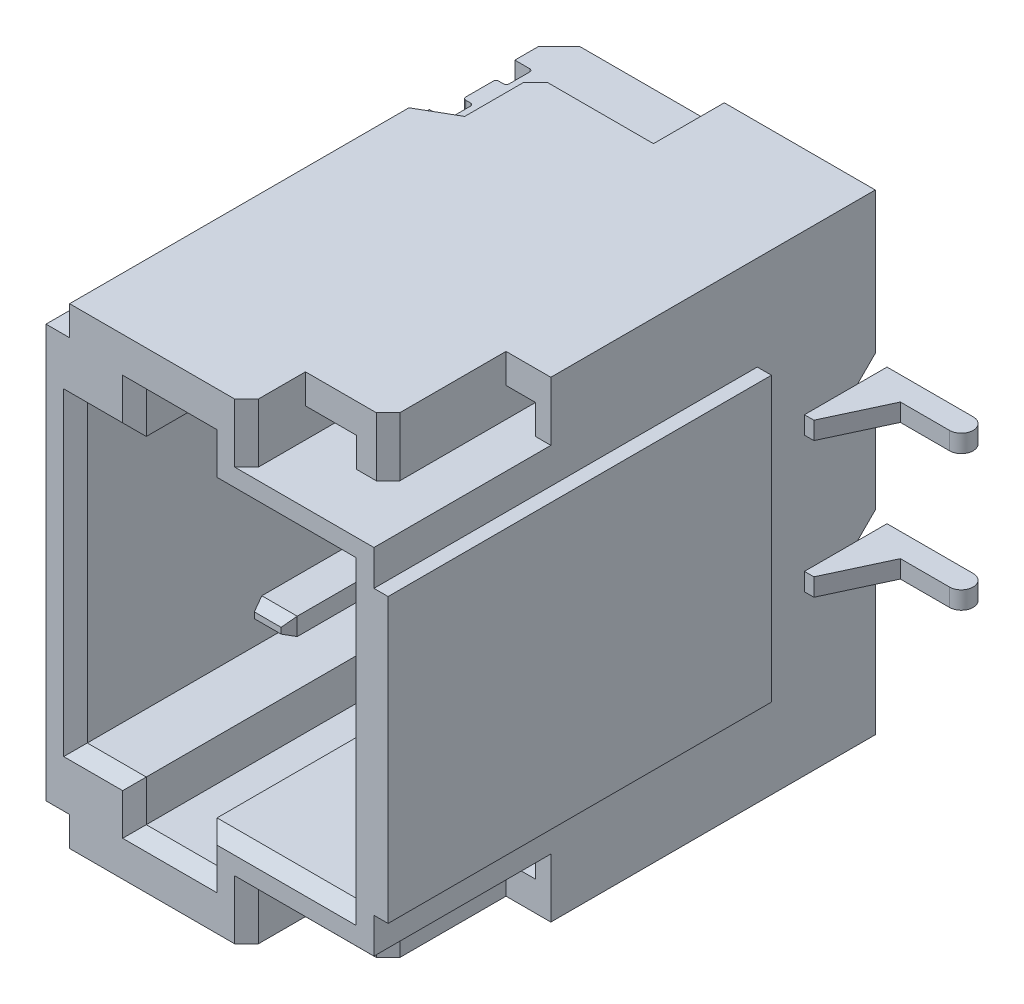
from build123d import *

# Parameters (mm, degrees)
BOSS_EXTRUDE2_START        = -0.815
BOSS_EXTRUDE2_DEPTH        = 0.15
BOSS_EXTRUDE3_START        = 2.26
BOSS_EXTRUDE3_DEPTH        = 0.2
BOSS_EXTRUDE4_START        = 1.76
SKETCH4_W                  = 2.899999619
SKETCH4_H                  = 6
BOSS_EXTRUDE4_DEPTH        = 4.25
SKETCH6_OUTSIDE_W          = 7.998
SKETCH6_OUTSIDE_H          = 9.648
SKETCH6_OUTSIDE_W_2        = 3.400752587
SKETCH6_OUTSIDE_H_2        = 4.399999618
CUT_EXTRUDE3_DEPTH         = 0.12
SKETCH7_W                  = 2.280000687
SKETCH7_H                  = 4.5
CUT_EXTRUDE4_DEPTH         = 3.2
SKETCH8_W                  = 0.600000381
SKETCH8_H                  = 0.349998474
SKETCH8_H_2                = 0.350000382
CUT_EXTRUDE6_DEPTH         = 2.6
CHAMFER1_SIZE              = 0.1
BOSS_EXTRUDE5_START        = -1.82
BOSS_EXTRUDE5_DEPTH        = 0.15
CHAMFER2_SIZE              = 0.1
CHAMFER2_SIZE2             = 0.05
CHAMFER3_SIZE              = 0.05
CHAMFER3_SIZE2             = 0.1
SKETCH10_W                 = 4.538557702
SKETCH10_H                 = 0.25
SKETCH10_W_2               = 4.80487801
CUT_EXTRUDE7_DEPTH         = 0.2
CUT_EXTRUDE8_DEPTH         = 0.5
SKETCH12_W                 = 0.600000143
SKETCH12_H                 = 0.25
CUT_EXTRUDE9_DEPTH         = 1
CHAMFER4_SIZE              = 0.1
CHAMFER5_SIZE              = 0.1
CHAMFER4_OF_MIRROR1_SIZE   = 0.1
CHAMFER5_OF_MIRROR1_SIZE   = 0.1
CUT_EXTRUDE10_DEPTH        = 0.5
CHAMFER6_SIZE              = 0.1
SKETCH14_W                 = 0.431049877
SKETCH14_H                 = 0.25
SKETCH14_W_2               = 0.251151421
CUT_EXTRUDE11_DEPTH        = 2
CHAMFER6_OF_MIRROR3_SIZE   = 0.1
SZKIC1_W                   = 5
SZKIC1_H                   = 2
WYTNIJ_WYCI_GNI_CIE1_DEPTH = 8.723710007
WYTNIJ_WYCI_GNI_CIE2_DEPTH = 8.723710007
SZYK_LINIOWY1_COUNT        = 2
SZYK_LINIOWY1_PITCH        = 1.15
SZYK_LINIOWY2_COUNT        = 2
SZYK_LINIOWY2_PITCH        = 1.15


with BuildPart() as part:
    # Sketch2 → Boss-Extrude2 (new body)
    with BuildSketch(Plane(origin=(0, 0, 0), x_dir=(1, 0, 0), z_dir=(0, 1, 0)).offset(BOSS_EXTRUDE2_START)):
        with BuildLine():
            Line((22.630613327, -2.360296965), (22.630613327, -1.910297036))
            Line((22.630613327, -1.910297036), (25.410614014, -1.910297036))
            Line((25.410614014, -1.910297036), (25.410614014, -1.660297036))
            Line((25.410614014, -1.660297036), (26.140613556, -1.660297036))
            ThreePointArc((26.140613556, -1.660297036), (26.24061352, -1.760297), (26.140613556, -1.860296965))
            Line((26.140613556, -1.860296965), (25.723766327, -1.860296965))
            Line((25.723766327, -1.860296965), (25.490613937, -2.360296965))
            Line((25.490613937, -2.360296965), (22.630613327, -2.360296965))
        make_face()
    extrude(amount=BOSS_EXTRUDE2_DEPTH)


with BuildPart() as body_2:
    # Sketch3 → Boss-Extrude3 (new body)
    with BuildSketch(Plane(origin=(0, 0, 0), x_dir=(1, 0, 0), z_dir=(0, 1, 0)).offset(BOSS_EXTRUDE3_START)):
        with BuildLine():
            Line((22.730613708, -2.960297108), (24.130613327, -2.960297108))
            Line((24.130613327, -2.960297108), (24.130613327, -1.835296988))
            Line((24.130613327, -1.835296988), (23.955612183, -1.660297036))
            Line((23.955612183, -1.660297036), (22.805612564, -1.660297036))
            Line((22.805612564, -1.660297036), (22.630613327, -1.835296988))
            Line((22.630613327, -1.835296988), (22.630613327, -2.035296917))
            Line((22.630613327, -2.035296917), (22.755613327, -2.035296917))
            ThreePointArc((22.755613327, -2.035296917), (22.773290756, -2.042619444), (22.780612946, -2.060297012))
            Line((22.780612946, -2.060297012), (22.780612946, -2.232796907))
            ThreePointArc((22.780612946, -2.232796907), (22.773287217, -2.250482782), (22.755601342, -2.257808511))
            Line((22.755601342, -2.257808511), (22.718101914, -2.257808511))
            ThreePointArc((22.718101914, -2.257808511), (22.700432315, -2.265127499), (22.693113327, -2.282797098))
            Line((22.693113327, -2.282797098), (22.693113327, -2.512797117))
            ThreePointArc((22.693113327, -2.512797117), (22.700435531, -2.530474601), (22.718112946, -2.537796974))
            Line((22.718112946, -2.537796974), (22.755613327, -2.537796974))
            ThreePointArc((22.755613327, -2.537796974), (22.773290895, -2.545119362), (22.780612946, -2.56279707))
            Line((22.780612946, -2.56279707), (22.780612946, -2.735296965))
            ThreePointArc((22.780612946, -2.735296965), (22.773290756, -2.752974533), (22.755613327, -2.76029706))
            Line((22.755613327, -2.76029706), (22.630613327, -2.76029706))
            Line((22.630613327, -2.76029706), (22.630613327, -2.860296965))
            Line((22.630613327, -2.860296965), (22.730613708, -2.960297108))
        make_face()
    extrude(amount=BOSS_EXTRUDE3_DEPTH)


with BuildPart() as body_3:
    # Sketch4 → Boss-Extrude4 (new body)
    with BuildSketch(Plane.XY.offset(BOSS_EXTRUDE4_START)):
        with Locations((24.080613137, -0.240909576)):
            Rectangle(SKETCH4_W, SKETCH4_H)
    extrude(amount=BOSS_EXTRUDE4_DEPTH)

    # Sketch6 outside → Cut-Extrude3 (cut)
    with BuildSketch(Plane(origin=(25.530612946, 0, 0), x_dir=(0, 0, -1), z_dir=(1, 0, 0))):
        with Locations((-3.835, -0.241)):
            Rectangle(SKETCH6_OUTSIDE_W, SKETCH6_OUTSIDE_H)
        with Locations((-4.460673354, -0.24091053)):
            Rectangle(SKETCH6_OUTSIDE_W_2, SKETCH6_OUTSIDE_H_2, mode=Mode.SUBTRACT)
    extrude(amount=-CUT_EXTRUDE3_DEPTH, mode=Mode.SUBTRACT)

    # Sketch7 → Cut-Extrude4 (cut)
    with BuildSketch(Plane.XY.offset(6.01)):
        with Locations((24.020613671, -0.240909576)):
            Rectangle(SKETCH7_W, SKETCH7_H)
    extrude(amount=-CUT_EXTRUDE4_DEPTH, mode=Mode.SUBTRACT)

    # Sketch8 → Cut-Extrude6 (cut)
    with BuildSketch(Plane.XY.offset(6.01)):
        with Locations((23.680613517, 2.184089661)):
            Rectangle(SKETCH8_W, SKETCH8_H)
        with Locations((23.680613517, -2.665909767)):
            Rectangle(SKETCH8_W, SKETCH8_H_2)
    extrude(amount=-CUT_EXTRUDE6_DEPTH, mode=Mode.SUBTRACT)

    # Chamfer1
    chamfer1_edges = [body_3.edges().sort_by_distance(p)[0] for p in [
        (22.880613327, -0.240909576, 6.01),
        (23.130613327, -2.490909576, 6.01),
        (25.160614014, -0.240909576, 6.01),
        (24.570613861, 2.009090424, 6.01),
        (24.570613861, -2.490909576, 6.01),
        (23.130613327, 2.009090424, 6.01),
        (23.380613327, 2.184089661, 6.01),
        (23.980613708, 2.184089661, 6.01),
        (23.680613518, 2.359088898, 6.01),
        (23.380613327, -2.665909767, 6.01),
        (23.680613518, -2.840909958, 6.01),
        (23.980613708, -2.665909767, 6.01),
    ]]
    chamfer(chamfer1_edges, length=CHAMFER1_SIZE)

    # Sketch10 → Cut-Extrude7 (cut)
    with BuildSketch(Plane.ZY.offset(-22.630613327)):
        with Locations((3.741017971, 2.634090424)):
            Rectangle(SKETCH10_W, SKETCH10_H)
        with Locations((3.607857817, -3.115909576)):
            Rectangle(SKETCH10_W_2, SKETCH10_H)
    extrude(amount=-CUT_EXTRUDE7_DEPTH, mode=Mode.SUBTRACT)

    # Sketch11 → Cut-Extrude8 (cut)
    with BuildSketch(Plane.XZ.offset(3.240909576)):
        Polygon((22.630613327, 3.248971939), (23.130613327, 2.960297108), (23.130613327, 2.360296965), (24.130613327, 2.360296965), (24.130613327, 1.643555377), (22.630613327, 1.643555377), align=None)
    cut_extrude8 = extrude(amount=-CUT_EXTRUDE8_DEPTH, mode=Mode.SUBTRACT)

    # Sketch12 → Cut-Extrude9 (cut)
    with BuildSketch(Plane.ZY.offset(-23.130613327)):
        with Locations((2.660297037, -2.865909576)):
            Rectangle(SKETCH12_W, SKETCH12_H)
    cut_extrude9 = extrude(amount=-CUT_EXTRUDE9_DEPTH, mode=Mode.SUBTRACT)

    # Chamfer4
    chamfer4_edges = [body_3.edges().sort_by_distance(p)[0] for p in [
        (22.630613327, -2.740909576, 2.50448597),
    ]]
    chamfer(chamfer4_edges, length=CHAMFER4_SIZE)

    # Chamfer5
    chamfer5_edges = [body_3.edges().sort_by_distance(p)[0] for p in [
        (23.130613327, -3.115909576, 2.360296965),
    ]]
    chamfer(chamfer5_edges, length=CHAMFER5_SIZE)

    # Mirror1: Cut-Extrude8, Cut-Extrude9 across plane
    add(cut_extrude8.mirror(Plane(origin=(0, -0.240909576, 0), x_dir=(0, 0, 1), z_dir=(0, -1, 0))), mode=Mode.SUBTRACT)
    add(cut_extrude9.mirror(Plane(origin=(0, -0.240909576, 0), x_dir=(0, 0, 1), z_dir=(0, -1, 0))), mode=Mode.SUBTRACT)

    # Chamfer4 of Mirror1
    chamfer4_of_mirror1_edges = [body_3.edges().sort_by_distance(p)[0] for p in [
        (22.630613327, 2.259090424, 2.50448597),
    ]]
    chamfer(chamfer4_of_mirror1_edges, length=CHAMFER4_OF_MIRROR1_SIZE)

    # Chamfer5 of Mirror1
    chamfer5_of_mirror1_edges = [body_3.edges().sort_by_distance(p)[0] for p in [
        (23.130613327, 2.634090424, 2.360296965),
    ]]
    chamfer(chamfer5_of_mirror1_edges, length=CHAMFER5_OF_MIRROR1_SIZE)

    # Sketch13 → Cut-Extrude10 (cut)
    with BuildSketch(Plane.XZ.offset(3.240909576)):
        Polygon((24.330612183, 5.510296822), (24.330612183, 6.069555527), (25.671033585, 6.069555527), (25.671033585, 4.510296822), (25.030612946, 4.510296822), (25.030612946, 5.510296822), align=None)
    cut_extrude10 = extrude(amount=-CUT_EXTRUDE10_DEPTH, mode=Mode.SUBTRACT)

    # Chamfer6
    chamfer6_edges = [body_3.edges().sort_by_distance(p)[0] for p in [
        (24.330612183, -2.990909576, 6.01),
        (25.030612946, -2.990909576, 5.510296822),
    ]]
    chamfer(chamfer6_edges, length=CHAMFER6_SIZE)

    # Sketch14 → Cut-Extrude11 (cut)
    with BuildSketch(Plane.XY.offset(5.510296822)):
        with Locations((24.546137122, -2.865909576)):
            Rectangle(SKETCH14_W, SKETCH14_H)
        with Locations((25.156188656, -2.865909576)):
            Rectangle(SKETCH14_W_2, SKETCH14_H)
    cut_extrude11 = extrude(amount=-CUT_EXTRUDE11_DEPTH, mode=Mode.SUBTRACT)

    # Mirror3: Cut-Extrude10, Cut-Extrude11 across plane
    add(cut_extrude10.mirror(Plane(origin=(0, -0.240909576, 0), x_dir=(0, 0, 1), z_dir=(0, -1, 0))), mode=Mode.SUBTRACT)
    add(cut_extrude11.mirror(Plane(origin=(0, -0.240909576, 0), x_dir=(0, 0, 1), z_dir=(0, -1, 0))), mode=Mode.SUBTRACT)

    # Chamfer6 of Mirror3
    chamfer6_of_mirror3_edges = [body_3.edges().sort_by_distance(p)[0] for p in [
        (24.330612183, 2.509090424, 6.01),
        (25.030612946, 2.509090424, 5.510296822),
    ]]
    chamfer(chamfer6_of_mirror3_edges, length=CHAMFER6_OF_MIRROR3_SIZE)

    # Szkic1 → Wytnij-wyci_gni_cie1 (cut, through all)
    with BuildSketch(Plane.ZY.offset(-22.630613327)):
        with Locations((3.947587466, -0.240909576)):
            Rectangle(SZKIC1_W, SZKIC1_H)
    extrude(amount=-WYTNIJ_WYCI_GNI_CIE1_DEPTH, mode=Mode.SUBTRACT)


with BuildPart() as body_4:
    # Sketch9 → Boss-Extrude5 (new body)
    with BuildSketch(Plane(origin=(0, 0, 0), x_dir=(1, 0, 0), z_dir=(0, 1, 0)).offset(BOSS_EXTRUDE5_START)):
        Polygon((23.360612869, -2.810297012), (23.660614014, -2.810297012), (23.660614014, -4.910296917), (23.62421608, -5.010296822), (23.397010803, -5.010296822), (23.360612869, -4.910296917), align=None)
    extrude(amount=BOSS_EXTRUDE5_DEPTH)

    # Chamfer2
    chamfer2_edges = [body_4.edges().sort_by_distance(p)[0] for p in [
        (23.510613441, -1.82, 5.010296822),
    ]]
    chamfer2_side = [body_4.faces().sort_by_distance(p)[0] for p in [
        (23.510613441, -1.82, 3.90438183),
    ]]
    chamfer(chamfer2_edges, length=CHAMFER2_SIZE, length2=CHAMFER2_SIZE2, reference=chamfer2_side[0])

    # Chamfer3
    chamfer3_edges = [body_4.edges().sort_by_distance(p)[0] for p in [
        (23.510613441, -1.67, 5.010296822),
    ]]
    chamfer3_side = [body_4.faces().sort_by_distance(p)[0] for p in [
        (23.510613441, -1.72, 5.010296822),
    ]]
    chamfer(chamfer3_edges, length=CHAMFER3_SIZE, length2=CHAMFER3_SIZE2, reference=chamfer3_side[0])


with BuildPart() as body_5:
    # Mirror2: mirrored copy
    add(body_2.part.mirror(Plane(origin=(0, -0.240909576, 0), x_dir=(0, 0, 1), z_dir=(0, -1, 0))))


with BuildPart() as wytnij_wyci_gni_cie1_piece_1:
    # of the separate pieces the step leaves, piece 1, a body of its own (wytnij_wyci_gni_cie1_pieces)
    add(body_3.part.solids().sort_by_distance((24.230612183, 2.759090424, 6.01))[0])


with BuildPart() as wytnij_wyci_gni_cie1_piece_2:
    # of the separate pieces the step leaves, piece 2, a body of its own (wytnij_wyci_gni_cie1_pieces)
    add(body_3.part.solids().sort_by_distance((22.630613327, -2.990909576, 6.01))[0])


with BuildPart() as wytnij_wyci_gni_cie1_piece_1_1:
    # Obiekt-Przenie_Kopiuj1: moved
    add(wytnij_wyci_gni_cie1_piece_1.part.moved(Location((0, -2, 0))))

    # Po_cz1: union Wytnij-wyci_gni_cie1 piece 2
    add(wytnij_wyci_gni_cie1_piece_2.part)

    # Sketch5 → Wytnij-wyci_gni_cie2 (cut, through all)
    with BuildSketch(Plane.ZY.offset(-22.630613327)):
        Polygon((1.760296941, -0.440910339), (1.910297036, -0.590909958), (2.360296965, -0.590909958), (2.360296965, -0.740909576), (1.910297036, -0.740909576), (1.760296941, -0.890909195), (1.752676685, -0.890909195), (1.752676685, -0.440910339), align=None)
        Polygon((1.752676685, -2.040908813), (1.760296941, -2.040908813), (1.910297036, -1.890909195), (2.360296965, -1.890909195), (2.360296965, -1.740909576), (1.910297036, -1.740909576), (1.760296941, -1.590909958), (1.752676685, -1.590909958), align=None)
    extrude(amount=-WYTNIJ_WYCI_GNI_CIE2_DEPTH, mode=Mode.SUBTRACT)


with BuildPart() as body_2_1:
    # Obiekt-Przenie_Kopiuj1: moved
    add(body_2.part.moved(Location((0, -2, 0))))


with BuildPart() as part_1:
    # Obiekt-Przenie_Kopiuj2: moved
    add(part.part.moved(Location((0, 0.074, 0))))


with BuildPart() as szyk_liniowy1_1:
    # Szyk liniowy1: pattern copy
    add(part_1.part.moved(Location(Vector(0, -1, 0) * (1 * SZYK_LINIOWY1_PITCH))))


with BuildPart() as szyk_liniowy2_1:
    # Szyk liniowy2: pattern copy
    add(body_4.part.moved(Location(Vector(0, 1, 0) * (1 * SZYK_LINIOWY2_PITCH))))


solid = Compound([body_4.part, body_5.part, wytnij_wyci_gni_cie1_piece_1_1.part, body_2_1.part, part_1.part, szyk_liniowy1_1.part, szyk_liniowy2_1.part])
